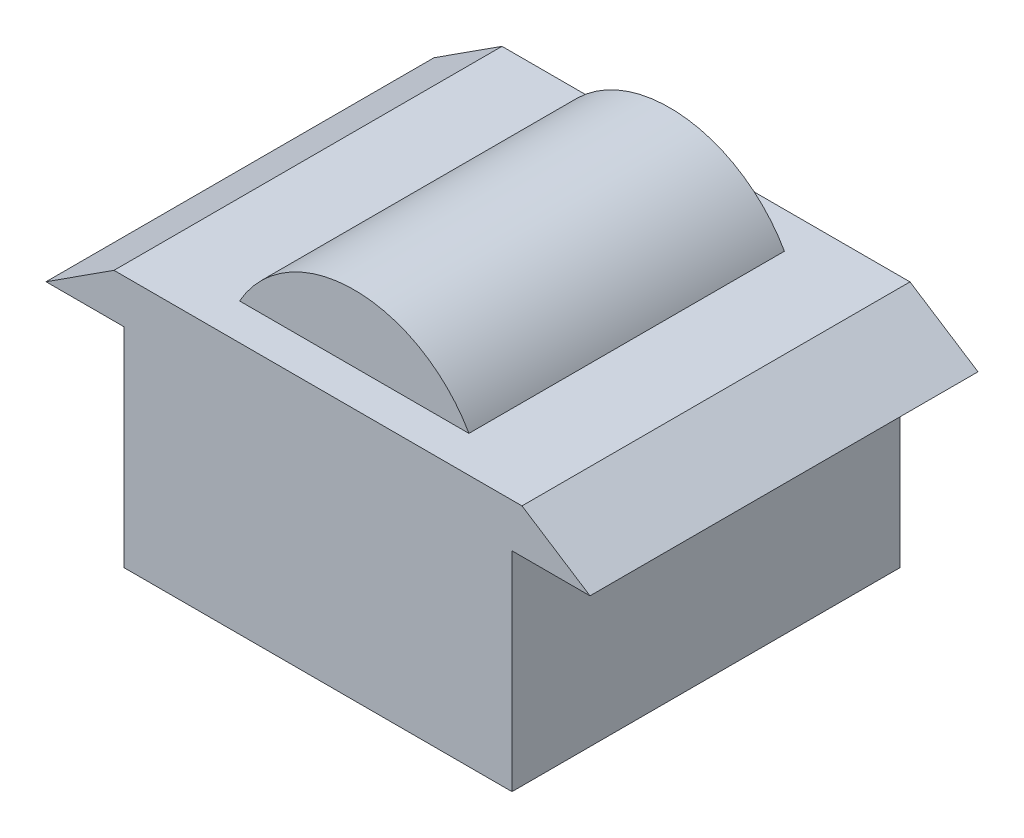
from build123d import *

# Parameters (mm, degrees)
BOSS_EXTRUDE1_DEPTH = 22.225
SKETCH2_W           = 26.27393882
SKETCH2_H           = 4.154599903
CUT_EXTRUDE1_DEPTH  = 44.45


with BuildPart() as part:
    # Sketch1 → Boss-Extrude1 (new body, symmetric)
    with BuildSketch(Plane.XY):
        with BuildLine():
            Line((-23.369890455, 7.407032893), (-13.13696941, 7.407032893))
            ThreePointArc((-13.13696941, 7.407032893), (0, 15.08125), (13.13696941, 7.407032893))
            Line((13.13696941, 7.407032893), (23.369890455, 7.407032893))
            Line((23.369890455, 7.407032893), (31.15985394, 2.38125))
            Line((31.15985394, 2.38125), (22.225, 2.38125))
            Line((22.225, 2.38125), (22.225, -21.51875))
            Line((22.225, -21.51875), (-22.225, -21.51875))
            Line((-22.225, -21.51875), (-22.225, 2.38125))
            Line((-22.225, 2.38125), (-31.15985394, 2.38125))
            Line((-31.15985394, 2.38125), (-23.369890455, 7.407032893))
        make_face()
    extrude(amount=BOSS_EXTRUDE1_DEPTH, both=True)

    # Sketch2 → Cut-Extrude1 (cut)
    with BuildSketch(Plane(origin=(0, 7.407032893, 0), x_dir=(1, 0, 0), z_dir=(0, 1, 0))):
        with Locations((0, 20.147700048)):
            Rectangle(SKETCH2_W, SKETCH2_H)
        with Locations((0, -20.147700048)):
            Rectangle(SKETCH2_W, SKETCH2_H)
    extrude(amount=CUT_EXTRUDE1_DEPTH, mode=Mode.SUBTRACT)


solid = part.part
